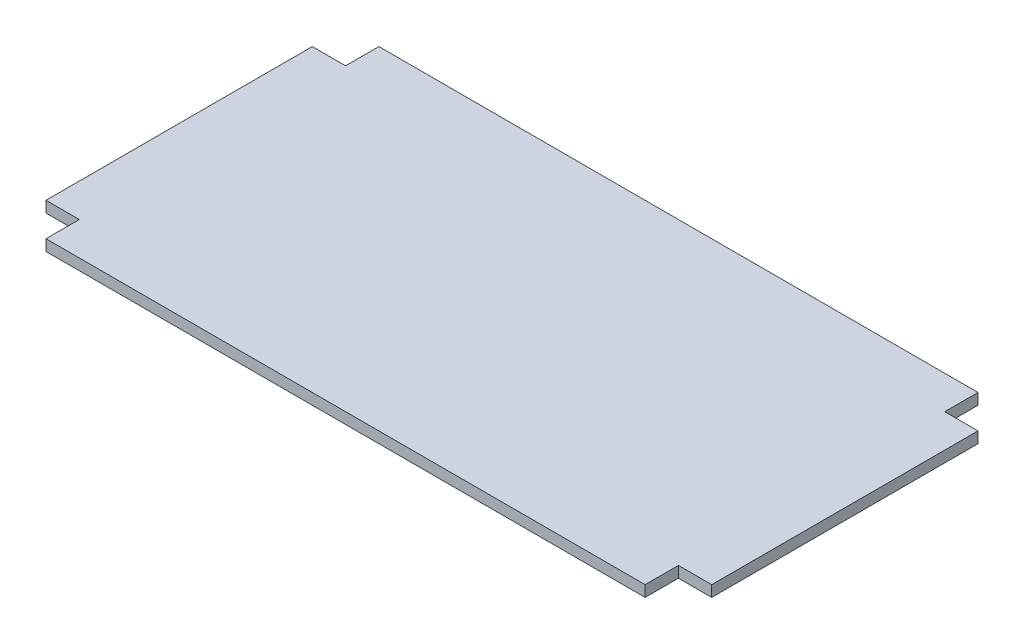
from build123d import *

# Parameters (mm, degrees)
BOSS_EXTRUDE1_DEPTH = 12.7


with BuildPart() as part:
    # Sketch1 → Boss-Extrude1 (new body)
    with BuildSketch(Plane(origin=(0, 0, 0), x_dir=(1, 0, 0), z_dir=(0, 1, 0))):
        Polygon((342.9, 190.5), (-342.9, 190.5), (-342.9, 152.4), (-381, 152.4), (-381, -152.4), (-342.9, -152.4), (-342.9, -190.5), (342.9, -190.5), (342.9, -152.4), (381, -152.4), (381, 152.4), (342.9, 152.4), align=None)
    extrude(amount=BOSS_EXTRUDE1_DEPTH)


solid = part.part
